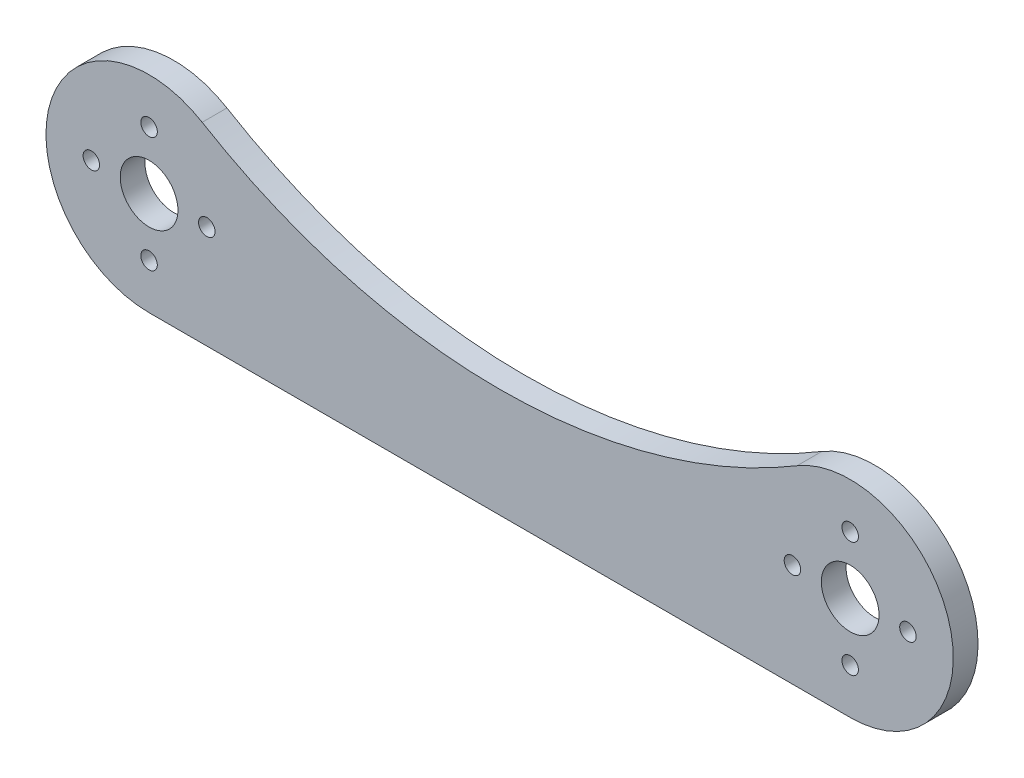
from build123d import *

# Parameters (mm, degrees)
SKETCH1_R           = 3.5
SKETCH1_R_2         = 1
BOSS_EXTRUDE1_DEPTH = 3


with BuildPart() as part:
    # Sketch1 → Boss-Extrude1 (new body)
    with BuildSketch(Plane.XY):
        with BuildLine():
            Line((-42.5, -12.5), (42.5, -12.5))
            ThreePointArc((42.5, -12.5), (54.545159585, 3.341276787), (36.060606061, 10.713739109))
            ThreePointArc((36.060606061, 10.713739109), (0, 0.710678119), (-36.060606061, 10.713739109))
            ThreePointArc((-36.060606061, 10.713739109), (-54.545159585, 3.341276787), (-42.5, -12.5))
        make_face()
        with Locations((-42.5, 0)):
            Circle(SKETCH1_R, mode=Mode.SUBTRACT)
        with Locations((42.5, 0)):
            Circle(SKETCH1_R, mode=Mode.SUBTRACT)
        with Locations((-42.5, 7)):
            Circle(SKETCH1_R_2, mode=Mode.SUBTRACT)
        with Locations((-35.5, 0)):
            Circle(SKETCH1_R_2, mode=Mode.SUBTRACT)
        with Locations((-42.5, -7)):
            Circle(SKETCH1_R_2, mode=Mode.SUBTRACT)
        with Locations((-49.5, 0)):
            Circle(SKETCH1_R_2, mode=Mode.SUBTRACT)
        with Locations((42.5, 7)):
            Circle(SKETCH1_R_2, mode=Mode.SUBTRACT)
        with Locations((35.5, 0)):
            Circle(SKETCH1_R_2, mode=Mode.SUBTRACT)
        with Locations((42.5, -7)):
            Circle(SKETCH1_R_2, mode=Mode.SUBTRACT)
        with Locations((49.5, 0)):
            Circle(SKETCH1_R_2, mode=Mode.SUBTRACT)
    extrude(amount=BOSS_EXTRUDE1_DEPTH)


solid = part.part
